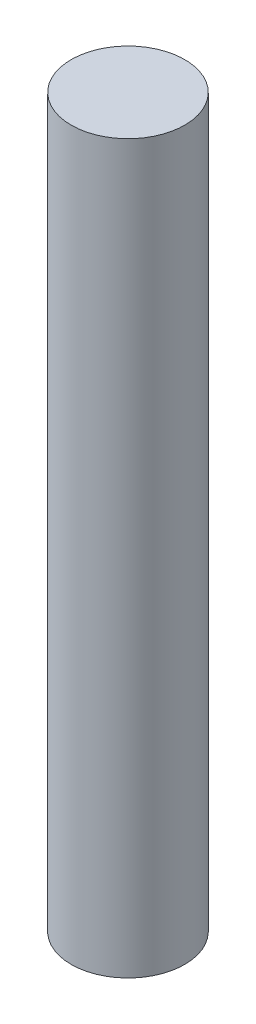
from build123d import *

# Parameters (mm, degrees)
SKETCH1_R           = 3.96875
BOSS_EXTRUDE1_DEPTH = 50.8


with BuildPart() as part:
    # Sketch1 → Boss-Extrude1 (new body)
    with BuildSketch(Plane(origin=(0, 0, 0), x_dir=(1, 0, 0), z_dir=(0, 1, 0))):
        Circle(SKETCH1_R)
    extrude(amount=BOSS_EXTRUDE1_DEPTH)


solid = part.part
